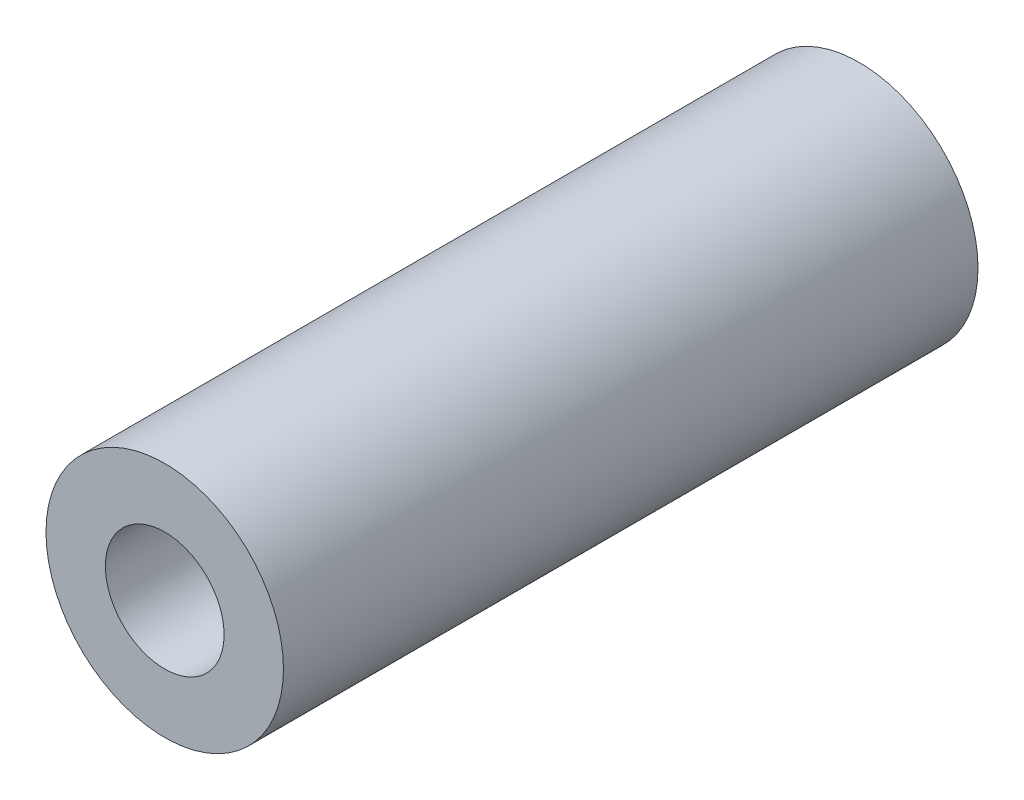
from build123d import *

# Parameters (mm, degrees)
CROQUIS1_R              = 2
CROQUIS1_R_2            = 1
SALIENTE_EXTRUIR1_DEPTH = 11.7


with BuildPart() as part:
    # Croquis1 → Saliente-Extruir1 (new body)
    with BuildSketch(Plane.XY):
        Circle(CROQUIS1_R)
        Circle(CROQUIS1_R_2, mode=Mode.SUBTRACT)
    extrude(amount=-SALIENTE_EXTRUIR1_DEPTH)


solid = part.part
